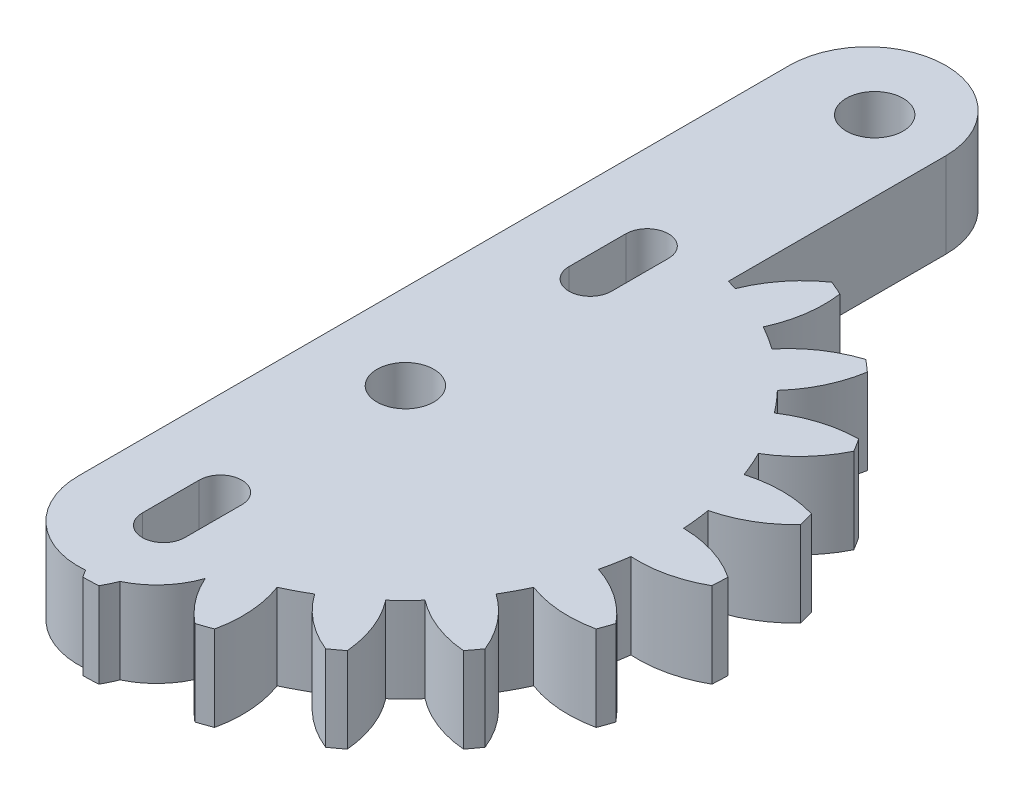
from build123d import *

# Parameters (mm, degrees)
BOSS_EXTRUDE1_DEPTH = 6
BOSS_EXTRUDE2_DEPTH = 6
SKETCH2_R           = 2
CUT_EXTRUDE1_DEPTH  = 7


with BuildPart() as part:
    # Sketch1 → Boss-Extrude1 (new body)
    with BuildSketch(Plane(origin=(0, 0, 0), x_dir=(1, 0, 0), z_dir=(0, 1, 0))):
        with BuildLine():
            Line((5, 33), (5, 0))
            Line((5, 0), (5, -17))
            ThreePointArc((5, -17), (-0.5, -22.5), (-6, -17))
            Line((-6, -17), (-6, 0))
            Line((-6, 0), (-6, 33))
            ThreePointArc((-6, 33), (-0.5, 38.5), (5, 33))
        make_face()
    extrude(amount=BOSS_EXTRUDE1_DEPTH)

    # Sketch4 → Boss-Extrude2 (add)
    with BuildSketch(Plane(origin=(0, 6, 0), x_dir=(1, 0, 0), z_dir=(0, 1, 0))):
        with BuildLine():
            Line((0, 18.405260039), (0, -22.486700485))
            ThreePointArc((0, -22.486700485), (0.153171428, -22.74508915), (0.315483204, -22.99783621))
            ThreePointArc((0.315483204, -22.99783621), (0.859997468, -22.98391621), (1.404029403, -22.957105685))
            ThreePointArc((1.404029403, -22.957105685), (2.272765962, -20.722115477), (2.474630782, -18.332735843))
            ThreePointArc((2.474630782, -18.332735843), (3.439178821, -18.176497188), (4.39413166, -17.969546682))
            ThreePointArc((4.39413166, -17.969546682), (5.454980724, -20.120007959), (7.080198393, -21.883116568))
            ThreePointArc((7.080198393, -21.883116568), (7.596418425, -21.709316597), (8.108378007, -21.52334096))
            ThreePointArc((8.108378007, -21.52334096), (8.279744109, -19.1315805), (7.76835863, -16.7888536))
            ThreePointArc((7.76835863, -16.7888536), (8.644002354, -16.355250664), (9.495529586, -15.876017098))
            ThreePointArc((9.495529586, -15.876017098), (11.143107691, -17.618248663), (13.215806885, -18.823985986))
            ThreePointArc((13.215806885, -18.823985986), (13.657864268, -18.505748935), (14.092261641, -18.177132938))
            ThreePointArc((14.092261641, -18.177132938), (13.551030657, -15.841120639), (12.371833724, -13.753208037))
            ThreePointArc((12.371833724, -13.753208037), (13.080768345, -13.080768345), (13.753208037, -12.371833724))
            ThreePointArc((13.753208037, -12.371833724), (15.841120639, -13.551030657), (18.177132938, -14.092261641))
            ThreePointArc((18.177132938, -14.092261641), (18.505748935, -13.657864268), (18.823985986, -13.215806885))
            ThreePointArc((18.823985986, -13.215806885), (17.618248663, -11.143107691), (15.876017098, -9.495529586))
            ThreePointArc((15.876017098, -9.495529586), (16.355250664, -8.644002354), (16.7888536, -7.76835863))
            ThreePointArc((16.7888536, -7.76835863), (19.1315805, -8.279744109), (21.52334096, -8.108378007))
            ThreePointArc((21.52334096, -8.108378007), (21.709316597, -7.596418425), (21.883116568, -7.080198393))
            ThreePointArc((21.883116568, -7.080198393), (20.120007959, -5.454980724), (17.969546682, -4.39413166))
            ThreePointArc((17.969546682, -4.39413166), (18.176497188, -3.439178821), (18.332735843, -2.474630782))
            ThreePointArc((18.332735843, -2.474630782), (20.722115477, -2.272765962), (22.957105685, -1.404029403))
            ThreePointArc((22.957105685, -1.404029403), (22.98391621, -0.859997468), (22.99783621, -0.315483204))
            ThreePointArc((22.99783621, -0.315483204), (20.834016252, 0.717845219), (18.466403185, 1.097704147))
            ThreePointArc((18.466403185, 1.097704147), (18.382682171, 2.071230843), (18.247674055, 3.038978872))
            ThreePointArc((18.247674055, 3.038978872), (20.471399556, 3.936157414), (22.351030824, 5.425073374))
            ThreePointArc((22.351030824, 5.425073374), (22.216294005, 5.952838037), (22.069097181, 6.477264053))
            ThreePointArc((22.069097181, 6.477264053), (19.696830773, 6.826887464), (17.322438727, 6.492004123))
            ThreePointArc((17.322438727, 6.492004123), (16.955485171, 7.397602558), (16.541226348, 8.282561916))
            ThreePointArc((16.541226348, 8.282561916), (18.401709947, 9.795335931), (19.758968788, 11.772134574))
            ThreePointArc((19.758968788, 11.772134574), (19.474656582, 12.23673776), (19.179422019, 12.694477974))
            ThreePointArc((19.179422019, 12.694477974), (16.809495442, 12.329330799), (14.63929957, 11.309461043))
            ThreePointArc((14.63929957, 11.309461043), (14.021718906, 12.066664821), (13.365018091, 12.790202986))
            ThreePointArc((13.365018091, 12.790202986), (14.696947654, 14.784155864), (15.411235665, 17.073189956))
            ThreePointArc((15.411235665, 17.073189956), (15.002610459, 17.433349632), (14.585571043, 17.783731818))
            ThreePointArc((14.585571043, 17.783731818), (12.428562673, 16.736258985), (10.655394403, 15.122022719))
            ThreePointArc((10.655394403, 15.122022719), (9.842061383, 15.663550962), (9.001269325, 16.161378393))
            ThreePointArc((9.001269325, 16.161378393), (9.686297066, 18.459338669), (9.694146621, 20.857217487))
            ThreePointArc((9.694146621, 20.857217487), (9.197516559, 21.080931885), (8.695728072, 21.292823047))
            ThreePointArc((8.695728072, 21.292823047), (6.913991789, 19.619372088), (5.689483487, 17.503810292))
            ThreePointArc((5.689483487, 17.503810292), (2.880227161, 18.178500725), (0, 18.405260039))
        make_face()
    extrude(amount=-BOSS_EXTRUDE2_DEPTH)

    # Sketch2 → Cut-Extrude1 (cut, through all)
    with BuildSketch(Plane(origin=(0, 6, 0), x_dir=(1, 0, 0), z_dir=(0, 1, 0))):
        Circle(SKETCH2_R)
        with Locations((0, 33)):
            Circle(SKETCH2_R)
        with BuildLine():
            Line((1.5, 17), (1.5, 13))
            ThreePointArc((1.5, 13), (0, 11.5), (-1.5, 13))
            Line((-1.5, 13), (-1.5, 17))
            ThreePointArc((-1.5, 17), (0, 18.5), (1.5, 17))
        make_face()
        with BuildLine():
            Line((-1.5, -17), (-1.5, -13))
            ThreePointArc((-1.5, -13), (0, -11.5), (1.5, -13))
            Line((1.5, -13), (1.5, -17))
            ThreePointArc((1.5, -17), (0, -18.5), (-1.5, -17))
        make_face()
    extrude(amount=-CUT_EXTRUDE1_DEPTH, mode=Mode.SUBTRACT)


solid = part.part
